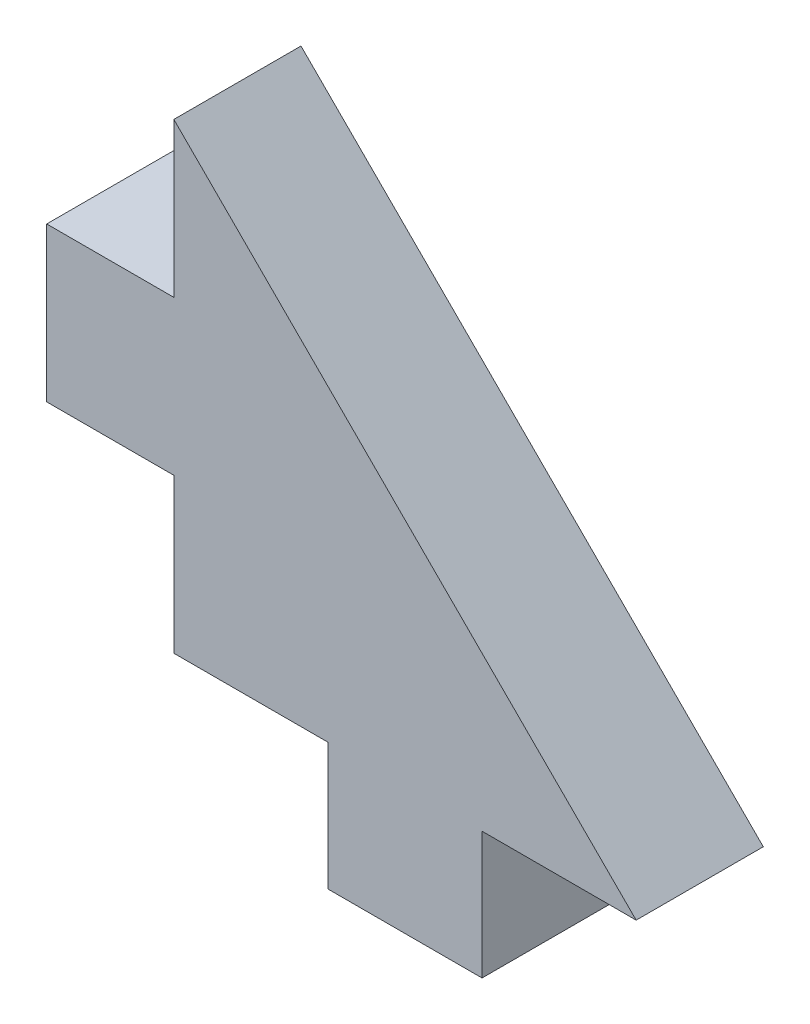
from build123d import *

# Parameters (mm, degrees)
BOSS_EXTRUDE1_DEPTH = 5.5


with BuildPart() as part:
    # Sketch1 → Boss-Extrude1 (new body)
    with BuildSketch(Plane.XY):
        Polygon((0, 20), (20, 0), (13.333333333, 0), (13.333333333, -5.5), (6.666666667, -5.5), (6.666666667, 0), (0, 0), (0, 6.666666667), (-5.5, 6.666666667), (-5.5, 13.333333333), (0, 13.333333333), align=None)
    extrude(amount=BOSS_EXTRUDE1_DEPTH)


solid = part.part
